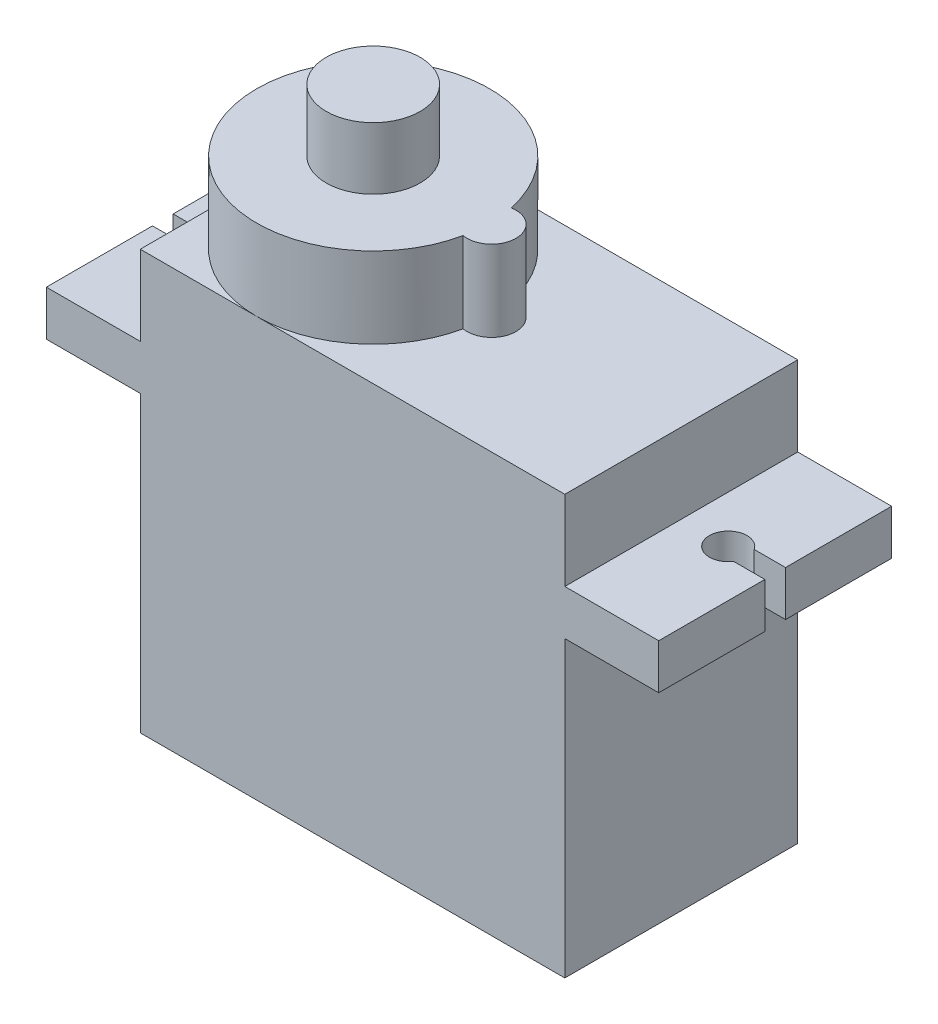
from build123d import *

# Parameters (mm, degrees)
SKETCH1_W             = 22.6
SKETCH1_H             = 12.4
BOSS_EXTRUDE1_DEPTH   = 22.3
SKETCH2_W             = 12.4
SKETCH2_H             = 2.4
BOSS_EXTRUDE2_DEPTH   = 5
SKETCH3_W             = 12.4
SKETCH3_H             = 2.4
BOSS_EXTRUDE3_DEPTH   = 5
CUT_EXTRUDE1_REACH    = 27.098
BOSS_EXTRUDE4_DEPTH   = 4.3
SKETCH7_R             = 2.5
BOSS_EXTRUDE5_DEPTH   = 3.3
SKETCH8_R             = 0.6
BOSS_EXTRUDE7_DEPTH   = 2.3
BOSS_EXTRUDE7_2_DEPTH = 2.3
BOSS_EXTRUDE7_3_DEPTH = 2.3


with BuildPart() as part:
    # Sketch1 → Boss-Extrude1 (new body)
    with BuildSketch(Plane(origin=(0, 0, 0), x_dir=(1, 0, 0), z_dir=(0, 1, 0))):
        Rectangle(SKETCH1_W, SKETCH1_H)
    extrude(amount=BOSS_EXTRUDE1_DEPTH)

    # Sketch2 → Boss-Extrude2 (add)
    with BuildSketch(Plane(origin=(11.3, 0, 0), x_dir=(0, 0, -1), z_dir=(1, 0, 0))):
        with Locations((0, 16.85)):
            Rectangle(SKETCH2_W, SKETCH2_H)
    extrude(amount=BOSS_EXTRUDE2_DEPTH)

    # Sketch3 → Boss-Extrude3 (add)
    with BuildSketch(Plane.ZY.offset(11.3)):
        with Locations((0, 16.85)):
            Rectangle(SKETCH3_W, SKETCH3_H)
    extrude(amount=BOSS_EXTRUDE3_DEPTH)

    # Sketch4 → Cut-Extrude1 (cut, up to next)
    with BuildSketch(Plane(origin=(0, 18.05, 0), x_dir=(1, 0, 0), z_dir=(0, 1, 0)), mode=Mode.PRIVATE) as cut_extrude1_sk1:
        with BuildLine():
            Line((-16.3, 0.55), (-14.635164654, 0.55))
            ThreePointArc((-14.635164654, 0.55), (-12.8, 0), (-14.635164654, -0.55))
            Line((-14.635164654, -0.55), (-16.3, -0.55))
            Line((-16.3, -0.55), (-16.3, 0.55))
        make_face()
    cut_extrude1_tool1 = extrude(cut_extrude1_sk1.sketch, amount=-CUT_EXTRUDE1_REACH, mode=Mode.PRIVATE) & part.part
    # Sketch4 → Cut-Extrude1 (cut, up to next)
    with BuildSketch(Plane(origin=(0, 18.05, 0), x_dir=(1, 0, 0), z_dir=(0, 1, 0)), mode=Mode.PRIVATE) as cut_extrude1_sk2:
        with BuildLine():
            Line((16.3, -0.55), (14.635164654, -0.55))
            ThreePointArc((14.635164654, -0.55), (12.8, 0), (14.635164654, 0.55))
            Line((14.635164654, 0.55), (16.3, 0.55))
            Line((16.3, 0.55), (16.3, -0.55))
        make_face()
    cut_extrude1_tool2 = extrude(cut_extrude1_sk2.sketch, amount=-CUT_EXTRUDE1_REACH, mode=Mode.PRIVATE) & part.part
    add(cut_extrude1_tool1.solids().sort_by_distance((-14.40681, 18.05, 0))[0], mode=Mode.SUBTRACT)
    add(cut_extrude1_tool2.solids().sort_by_distance((14.40681, 18.05, 0))[0], mode=Mode.SUBTRACT)

    # Sketch6 → Boss-Extrude4 (add)
    with BuildSketch(Plane(origin=(0, 22.3, 0), x_dir=(1, 0, 0), z_dir=(0, 1, 0))):
        with BuildLine():
            ThreePointArc((1.2, -1.3), (2.5, 0), (1.2, 1.3))
            ThreePointArc((1.2, 1.3), (1.082856772, 1.294711344), (0.966666667, 1.278888406))
            ThreePointArc((0.966666667, 1.278888406), (0.964431433, 1.289446156), (0.962177826, 1.3))
            ThreePointArc((0.962177826, 1.3), (-11.3, 0), (0.962177826, -1.3))
            ThreePointArc((0.962177826, -1.3), (0.964431433, -1.289446156), (0.966666667, -1.278888406))
            ThreePointArc((0.966666667, -1.278888406), (1.082856772, -1.294711344), (1.2, -1.3))
        make_face()
    extrude(amount=BOSS_EXTRUDE4_DEPTH)

    # Sketch7 → Boss-Extrude5 (add)
    with BuildSketch(Plane(origin=(0, 26.6, 0), x_dir=(1, 0, 0), z_dir=(0, 1, 0))):
        with Locations((-5.1, 0)):
            Circle(SKETCH7_R)
    extrude(amount=BOSS_EXTRUDE5_DEPTH)


with BuildPart() as body_2:
    # Sketch8 → Boss-Extrude7 (new body)
    with BuildSketch(Plane.ZY.offset(11.3)):
        with Locations((-1.2, 4.5)):
            Circle(SKETCH8_R)
    extrude(amount=BOSS_EXTRUDE7_DEPTH)


with BuildPart() as body_3:
    # Sketch8 → Boss-Extrude7 2 (new body)
    with BuildSketch(Plane.ZY.offset(11.3)):
        with Locations((1.2, 4.5)):
            Circle(SKETCH8_R)
    extrude(amount=BOSS_EXTRUDE7_2_DEPTH)


with BuildPart() as body_4:
    # Sketch8 → Boss-Extrude7 3 (new body)
    with BuildSketch(Plane.ZY.offset(11.3)):
        with BuildLine():
            ThreePointArc((0.6, 4.5), (0, 5.1), (-0.6, 4.5))
            ThreePointArc((-0.6, 4.5), (0, 3.9), (0.6, 4.5))
        make_face()
    extrude(amount=BOSS_EXTRUDE7_3_DEPTH)


solid = Compound([part.part, body_2.part, body_3.part, body_4.part])
